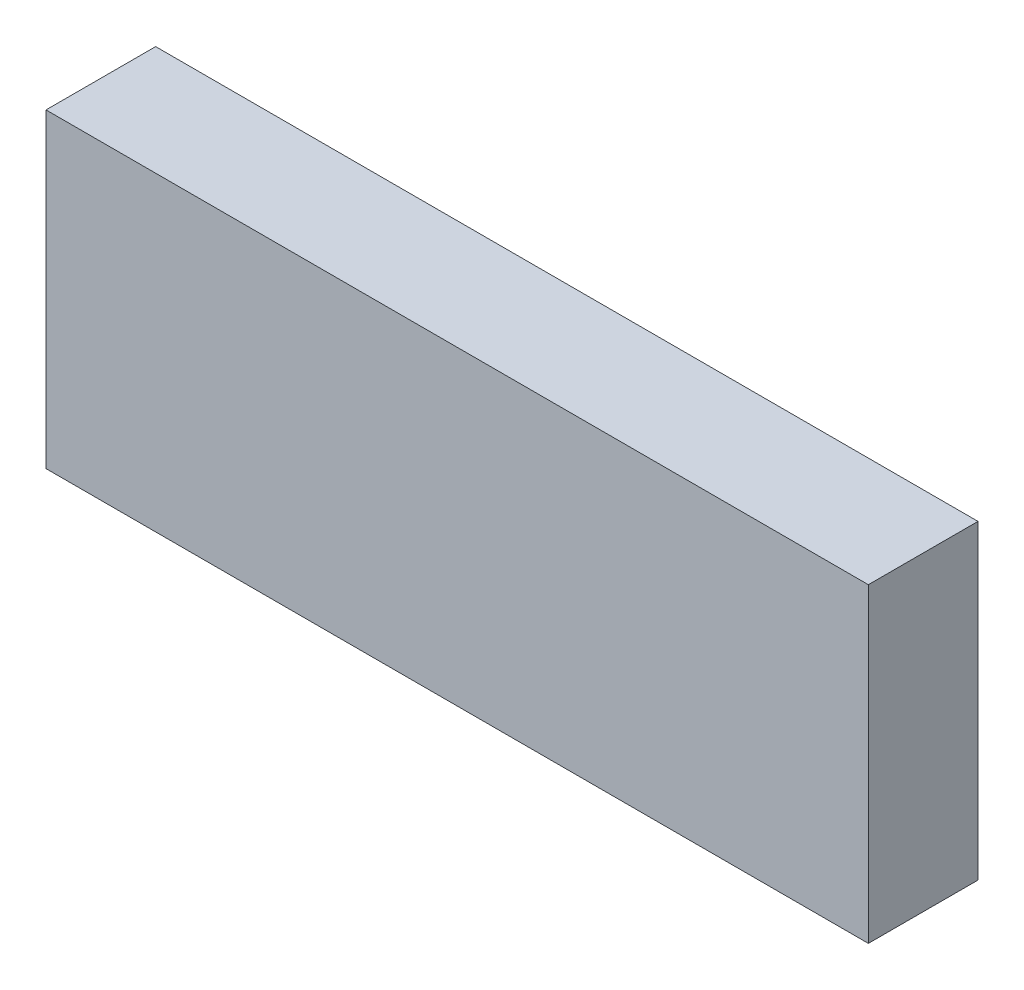
from build123d import *

# Parameters (mm, degrees)
SKETCH1_W           = 45
SKETCH1_H           = 17
BOSS_EXTRUDE1_DEPTH = 6


with BuildPart() as part:
    # Sketch1 → Boss-Extrude1 (new body)
    with BuildSketch(Plane.XY):
        with Locations((-0.986594838, 9.425824176)):
            Rectangle(SKETCH1_W, SKETCH1_H)
    extrude(amount=BOSS_EXTRUDE1_DEPTH)


solid = part.part
